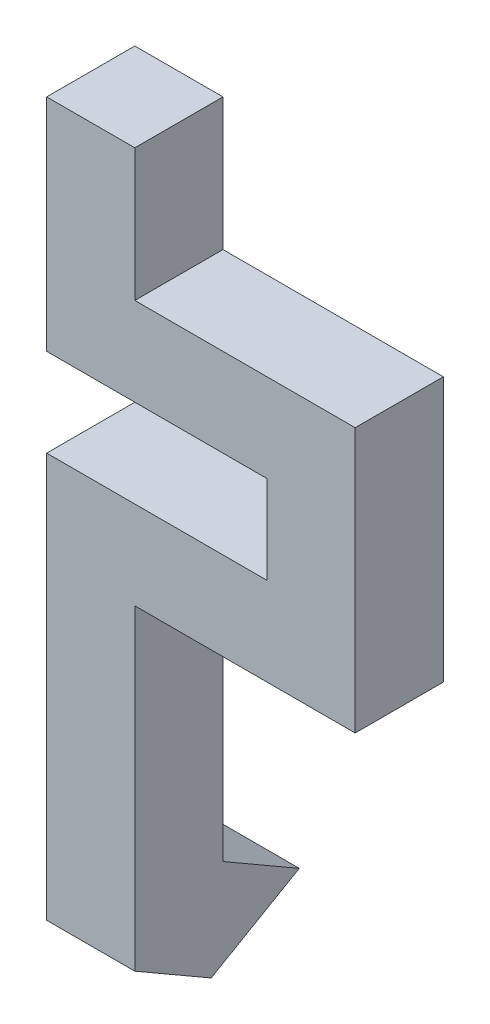
from build123d import *

# Parameters (mm, degrees)
SKETCH_1_W      = 2
SKETCH_1_H      = 7.18
SKETCH_1_H_2    = 5
EXTRUDE_1_DEPTH = 2
EXTRUDE_2_DEPTH = 2


with BuildPart() as part:
    # 草图1 → 凸台-拉伸1 (new body)
    with BuildSketch(Plane.XY):
        with Locations((1, -12.59)):
            Rectangle(SKETCH_1_W, SKETCH_1_H)
        Polygon((5, -9), (5, -7), (0, -7), (0, -9), (2, -9), align=None)
        Polygon((7, -5), (5, -5), (5, -7), (5, -9), (7, -9), align=None)
        with Locations((1, -2.5)):
            Rectangle(SKETCH_1_W, SKETCH_1_H_2)
        Polygon((7, -3), (2, -3), (2, -5), (5, -5), (7, -5), align=None)
    extrude(amount=EXTRUDE_1_DEPTH)

    # 草图2 → 凸台-拉伸2 (add)
    with BuildSketch(Plane.ZY):
        Polygon((2, -16.18), (0.267949192, -17.18), (-1.732050808, -16.025299462), (0, -15.025299462), align=None)
    extrude(amount=-EXTRUDE_2_DEPTH)


solid = part.part
